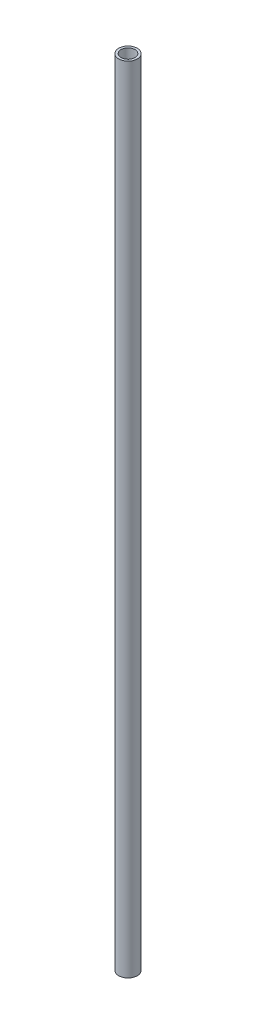
from build123d import *

# Parameters (mm, degrees)
SKETCH1_R           = 2
SKETCH1_R_2         = 1.5
BOSS_EXTRUDE1_DEPTH = 85.5


with BuildPart() as part:
    # Sketch1 → Boss-Extrude1 (new body, symmetric)
    with BuildSketch(Plane(origin=(0, 0, 0), x_dir=(1, 0, 0), z_dir=(0, 1, 0))):
        Circle(SKETCH1_R)
        Circle(SKETCH1_R_2, mode=Mode.SUBTRACT)
    extrude(amount=BOSS_EXTRUDE1_DEPTH, both=True)


solid = part.part
